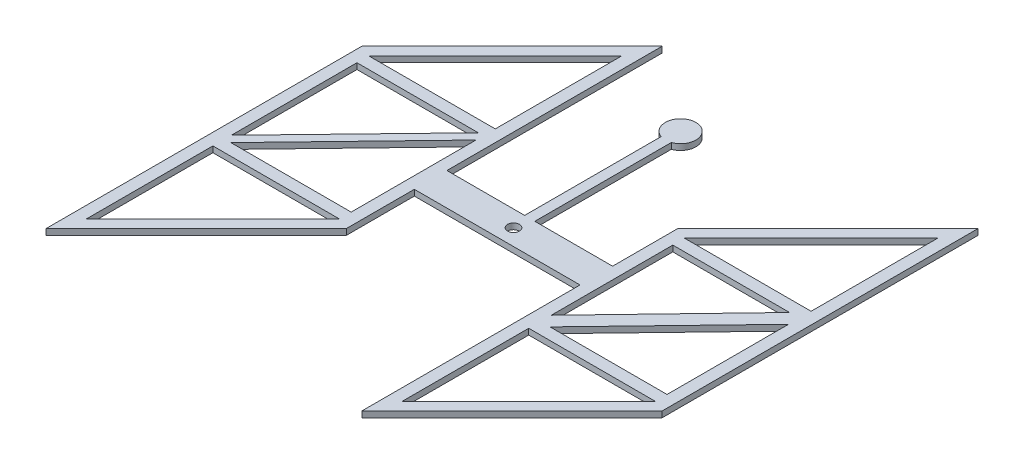
from build123d import *

# Parameters (mm, degrees)
SKETCH1_R           = 12.7
BOSS_EXTRUDE1_DEPTH = 12.7


with BuildPart() as part:
    # Sketch1 → Boss-Extrude1 (new body)
    with BuildSketch(Plane(origin=(0, 0, 0), x_dir=(1, 0, 0), z_dir=(0, 1, 0))):
        with BuildLine():
            Line((-177.80483956, -180.970122773), (-177.80483956, -34.920560393))
            Line((-177.80483956, -34.920560393), (177.79516044, -34.920560393))
            Line((177.79516044, -34.920560393), (177.79516044, -503.170122773))
            Line((177.79516044, -503.170122773), (499.99516044, -180.970122773))
            Line((499.99516044, -180.970122773), (499.99516044, 496.829877227))
            Line((499.99516044, 496.829877227), (177.795656663, 174.63037345))
            Line((177.795656663, 174.63037345), (177.795656663, 34.887353965))
            Line((177.795656663, 34.887353965), (10.941991643, 34.887353965))
            Line((10.941991643, 34.887353965), (10.941991643, 327.760499625))
            ThreePointArc((10.941991643, 327.760499625), (0.004607764, 391.44950084), (-10.950678316, 327.76357658))
            Line((-10.950678316, 327.76357658), (-10.950678316, 34.887353965))
            Line((-10.950678316, 34.887353965), (-177.804343337, 34.887353965))
            Line((-177.804343337, 34.887353965), (-177.804343337, 496.829877227))
            Line((-177.804343337, 496.829877227), (-500.00483956, 174.629381004))
            Line((-500.00483956, 174.629381004), (-500.00483956, -503.170122773))
            Line((-500.00483956, -503.170122773), (-177.80483956, -180.970122773))
        make_face()
        Polygon((-461.454447779, -145.049098288), (-203.204343337, 122.90730747), (-203.204343337, 9.487353965), (-203.20483956, -9.520560393), (-203.20483956, -145.049098288), align=None, mode=Mode.SUBTRACT)
        Polygon((-203.204343337, 164.10835652), (-474.60483956, 164.10835652), (-203.204343337, 435.508852743), align=None, mode=Mode.SUBTRACT)
        Polygon((-474.60483956, 138.70835652), (-214.240958944, 138.70835652), (-474.60483956, -130.828873379), align=None, mode=Mode.SUBTRACT)
        Polygon((-474.60483956, -170.449098288), (-203.20483956, -170.449098288), (-474.60483956, -441.849098288), align=None, mode=Mode.SUBTRACT)
        Polygon((474.59516044, 9.487353965), (474.594664217, -9.520560393), (474.594664217, -145.049098288), (223.497797401, -145.049098288), (474.59516044, 115.721361844), align=None, mode=Mode.SUBTRACT)
        Polygon((474.594664217, -170.449098288), (203.194664217, -441.849098288), (203.194664217, -170.449098288), align=None, mode=Mode.SUBTRACT)
        Polygon((203.194664217, -122.149307614), (203.194664217, 138.70835652), (453.645393175, 138.70835652), align=None, mode=Mode.SUBTRACT)
        Polygon((203.194664217, 164.10835652), (474.59516044, 435.508852743), (474.59516044, 164.10835652), align=None, mode=Mode.SUBTRACT)
        Circle(SKETCH1_R, mode=Mode.SUBTRACT)
    extrude(amount=BOSS_EXTRUDE1_DEPTH)


solid = part.part
